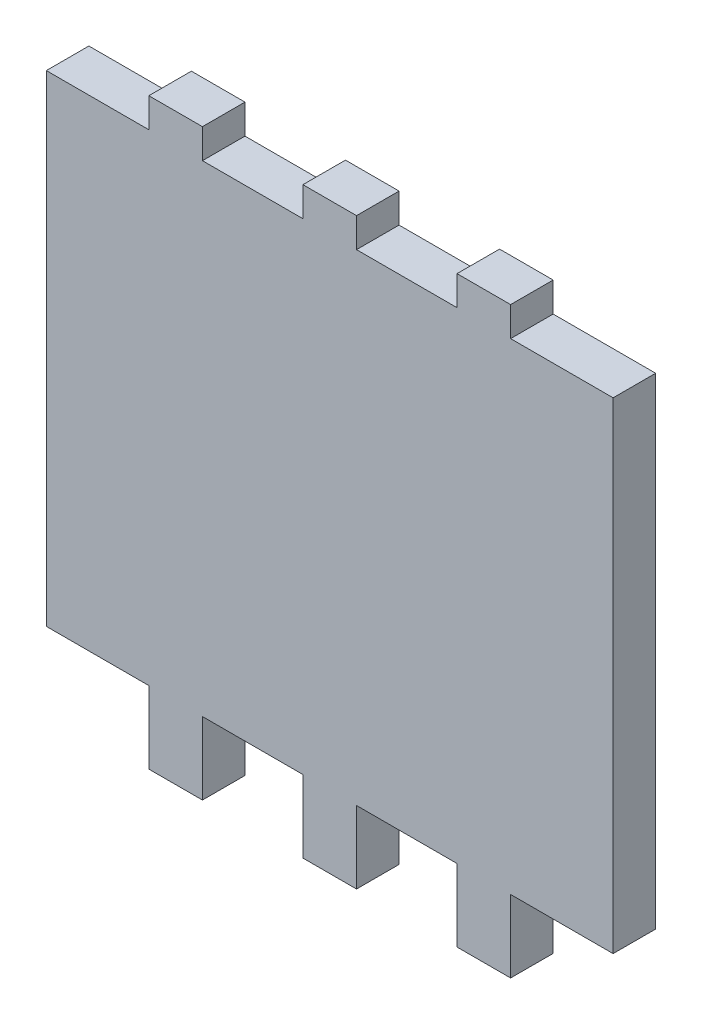
from build123d import *

# Parameters (mm, degrees)
BOSS_EXTRUDE1_DEPTH = 3.175


with BuildPart() as part:
    # Sketch1 → Boss-Extrude1 (new body)
    with BuildSketch(Plane.XY):
        Polygon((-9.5, 43.525), (-13.5, 43.525), (-13.5, 41.325), (-21.15, 41.325), (-21.15, 5.4), (-13.5, 5.4), (-13.5, 0), (-9.5, 0), (-9.5, 5.4), (-2, 5.4), (-2, 0), (2, 0), (2, 5.4), (9.5, 5.4), (9.5, 0), (13.5, 0), (13.5, 5.4), (21.15, 5.4), (21.15, 41.325), (13.5, 41.325), (13.5, 43.525), (9.5, 43.525), (9.5, 41.325), (2, 41.325), (2, 43.525), (-2, 43.525), (-2, 41.325), (-9.5, 41.325), align=None)
    extrude(amount=BOSS_EXTRUDE1_DEPTH)


solid = part.part
